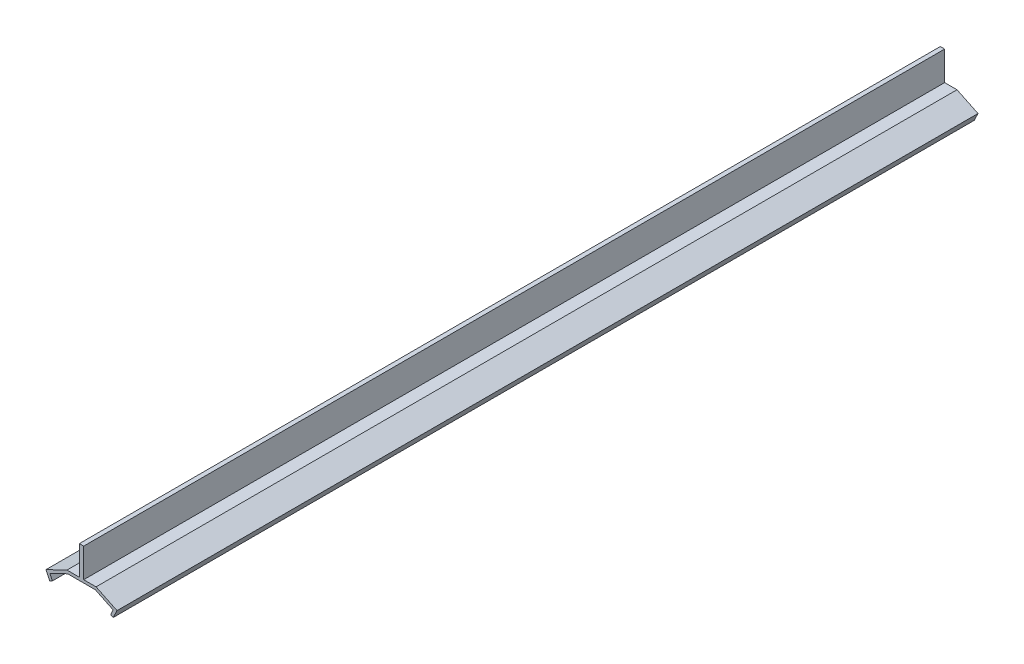
from build123d import *

# Parameters (mm, degrees)
EXTRUSION1_DEPTH = 148


with BuildPart() as part:
    # Esquisse1 → Extrusion1 (new body, symmetric)
    with BuildSketch(Plane.XY):
        Polygon((-0.75, 0), (-0.75, 10), (0.75, 10), (0.75, 0), (5, 0), (12.207425429, -3.47174577), (10.905520765, -6.174530306), (10.004592586, -5.740562084), (10.872529029, -3.938705727), (4.771707198, -1), (-4.771707198, -1), (-10.872529029, -3.938705727), (-10.004592586, -5.740562084), (-10.905520765, -6.174530306), (-12.207425429, -3.47174577), (-5, 0), align=None)
    extrude(amount=EXTRUSION1_DEPTH, both=True)


solid = part.part
